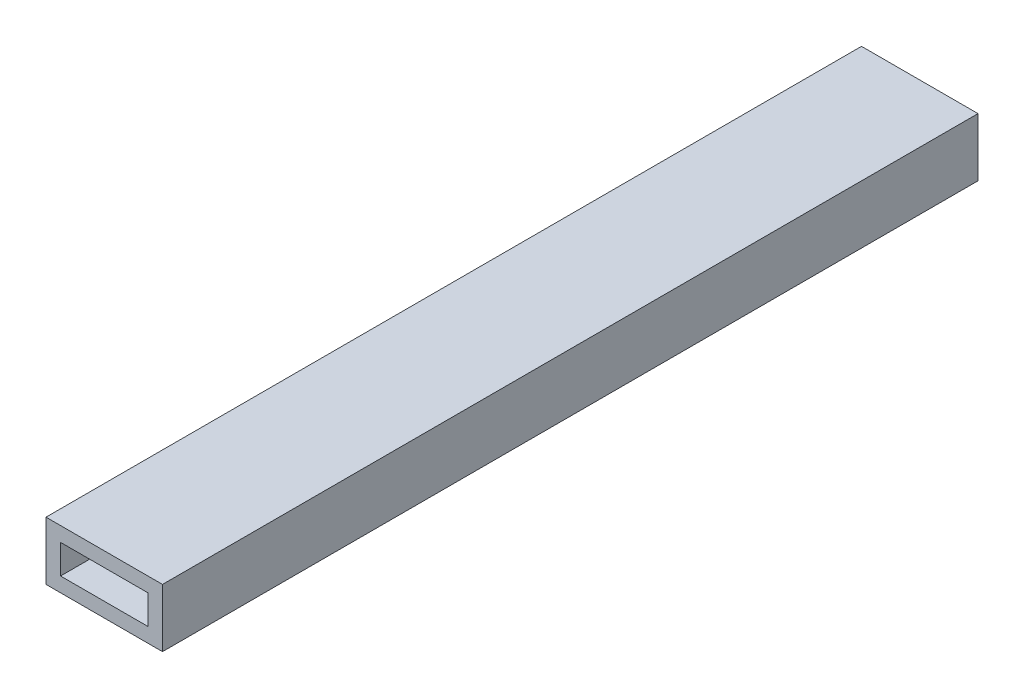
from build123d import *

# Parameters (mm, degrees)
SKETCH1_W           = 25.4
SKETCH1_H           = 12.7
SKETCH1_W_2         = 19.05
SKETCH1_H_2         = 6.35
BOSS_EXTRUDE1_DEPTH = 177.8


with BuildPart() as part:
    # Sketch1 → Boss-Extrude1 (new body)
    with BuildSketch(Plane.XY):
        with Locations((12.7, 6.35)):
            Rectangle(SKETCH1_W, SKETCH1_H)
        with Locations((12.7, 6.35)):
            Rectangle(SKETCH1_W_2, SKETCH1_H_2, mode=Mode.SUBTRACT)
    extrude(amount=BOSS_EXTRUDE1_DEPTH)


solid = part.part
